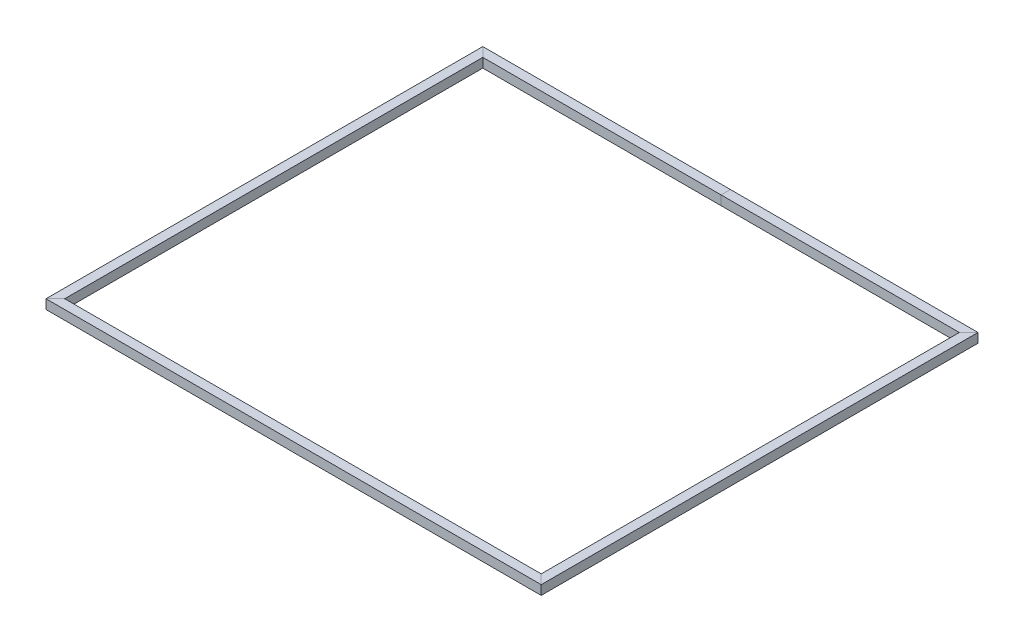
from build123d import *

# Parameters (mm, degrees)
SKETCH1_W   = 50.8
SKETCH1_H   = 50.8
SKETCH1_W_2 = 47.625
SKETCH1_H_2 = 47.625


with BuildPart() as part:
    # Sweep1: sweep along a path in Sketch2
    with BuildLine(Plane(origin=(0, 0, 0), x_dir=(1, 0, 0), z_dir=(0, 1, 0))) as sweep1_path:
        Line((1320.8, -1162.05), (-1320.8, -1162.05))
        Line((-1320.8, -1162.05), (-1320.8, 1162.05))
        Line((-1320.8, 1162.05), (1320.8, 1162.05))
        Line((1320.8, 1162.05), (1320.8, -1162.05))
    # Sketch1 → Sweep1 (sweep)
    with BuildSketch(Plane(origin=(0, 0, 0), x_dir=(0, 0, -1), z_dir=(1, 0, 0))):
        with Locations((1162.05, 0)):
            Rectangle(SKETCH1_W, SKETCH1_H)
        with Locations((1162.05, 0)):
            Rectangle(SKETCH1_W_2, SKETCH1_H_2, mode=Mode.SUBTRACT)
    sweep(path=sweep1_path.line, transition=Transition.RIGHT)


solid = part.part
